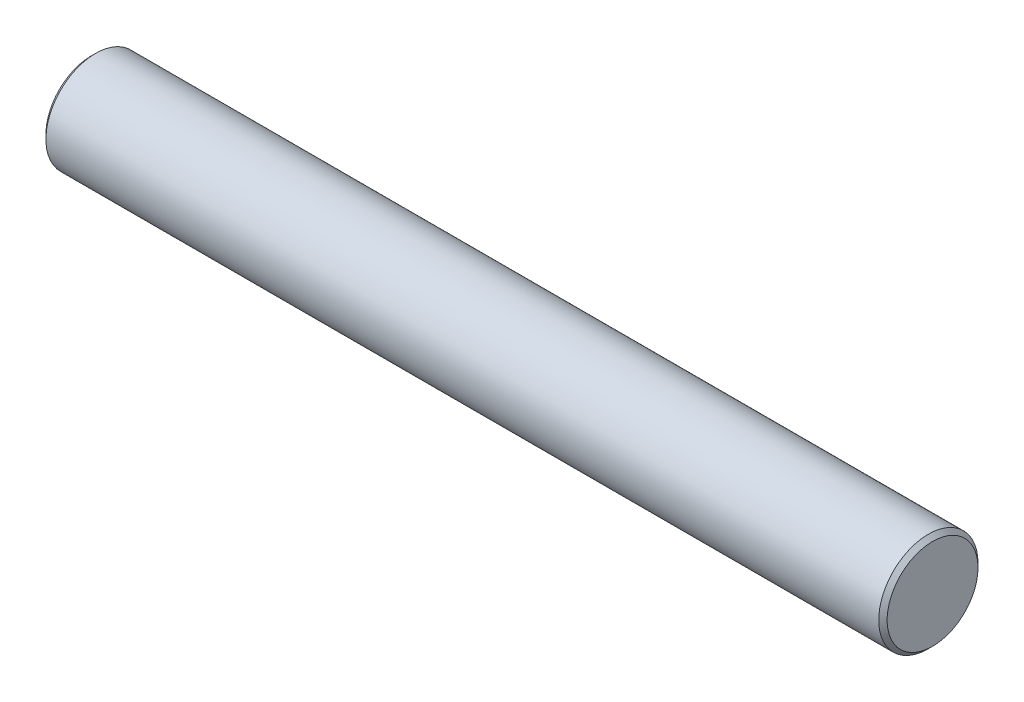
from build123d import *


with BuildPart() as part:
    # Sketch1 → Revolve1 (revolve)
    with BuildSketch(Plane.XY):
        Polygon((-12.573, 1.4986), (12.573, 1.4986), (12.7, 1.3716), (12.7, 0), (-12.7, 0), (-12.7, 1.3716), align=None)
    revolve(axis=Axis((12.7, 0, 0), (-1, 0, 0)))


solid = part.part
